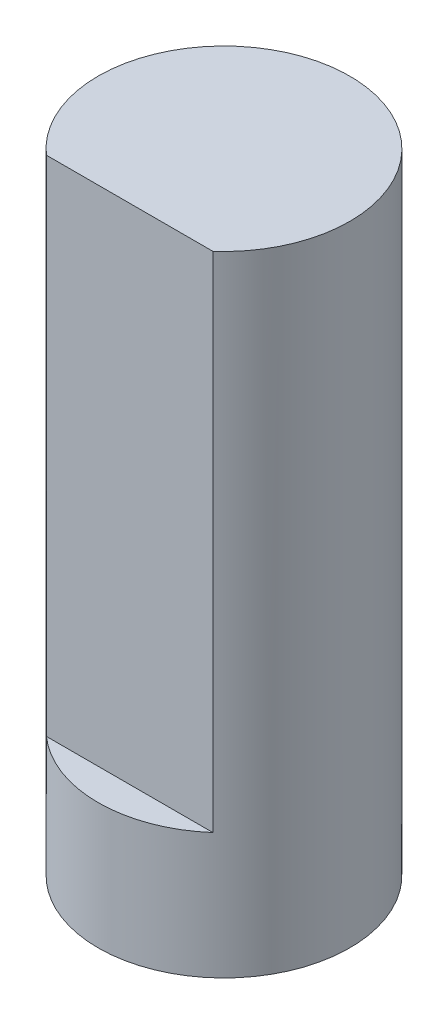
from build123d import *

# Parameters (mm, degrees)
SKETCH2_R           = 2
BOSS_EXTRUDE1_DEPTH = 10
CUT_EXTRUDE1_DEPTH  = 8


with BuildPart() as part:
    # Sketch2 → Boss-Extrude1 (new body)
    with BuildSketch(Plane(origin=(0, 0, 0), x_dir=(1, 0, 0), z_dir=(0, 1, 0))):
        Circle(SKETCH2_R)
    extrude(amount=BOSS_EXTRUDE1_DEPTH)

    # Sketch3 → Cut-Extrude1 (cut)
    with BuildSketch(Plane(origin=(0, 10, 0), x_dir=(1, 0, 0), z_dir=(0, 1, 0))):
        with BuildLine():
            Line((-1.322875656, -1.5), (1.322875656, -1.5))
            ThreePointArc((1.322875656, -1.5), (0, -2), (-1.322875656, -1.5))
        make_face()
    extrude(amount=-CUT_EXTRUDE1_DEPTH, mode=Mode.SUBTRACT)


solid = part.part
